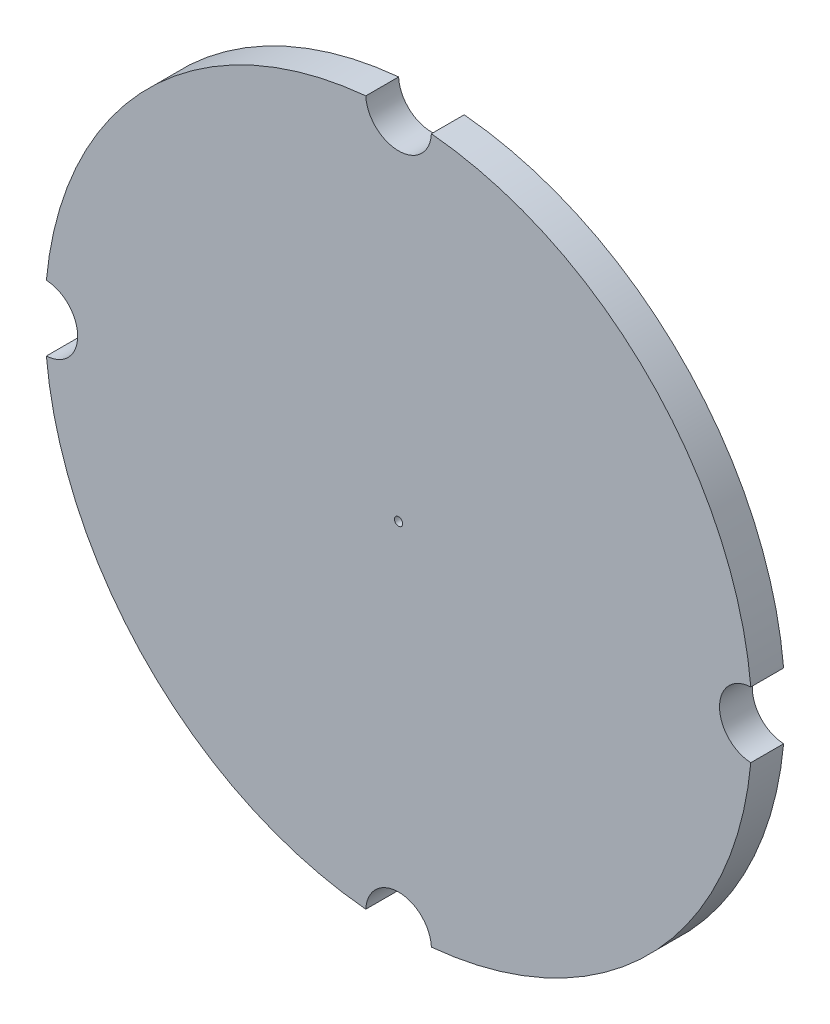
from build123d import *

# Parameters (mm, degrees)
SKETCH1_R           = 2.5
BOSS_EXTRUDE1_DEPTH = 20


with BuildPart() as part:
    # Sketch1 → Boss-Extrude1 (new body)
    with BuildSketch(Plane.XY):
        with BuildLine():
            ThreePointArc((214.598185251, -19.978460581), (195.526146906, 0), (214.598185251, 19.978460581))
            ThreePointArc((214.598185251, 19.978460581), (152.4, 152.4), (19.978460581, 214.598185251))
            ThreePointArc((19.978460581, 214.598185251), (0, 195.526146906), (-19.978460581, 214.598185251))
            ThreePointArc((-19.978460581, 214.598185251), (-152.4, 152.4), (-214.598185251, 19.978460581))
            ThreePointArc((-214.598185251, 19.978460581), (-201.059647103, 13.810155084), (-195.526146906, 0))
            ThreePointArc((-195.526146906, 0), (-201.059647103, -13.810155084), (-214.598185251, -19.978460581))
            ThreePointArc((-214.598185251, -19.978460581), (-152.4, -152.4), (-19.978460581, -214.598185251))
            ThreePointArc((-19.978460581, -214.598185251), (0, -195.526146906), (19.978460581, -214.598185251))
            ThreePointArc((19.978460581, -214.598185251), (152.4, -152.4), (214.598185251, -19.978460581))
        make_face()
        Circle(SKETCH1_R, mode=Mode.SUBTRACT)
    extrude(amount=BOSS_EXTRUDE1_DEPTH)


solid = part.part
